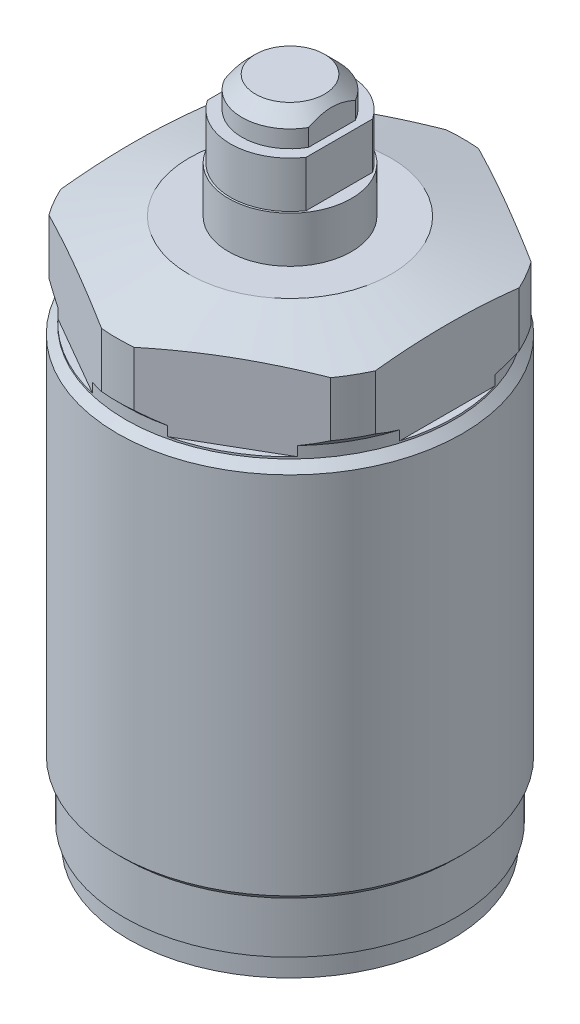
from build123d import *

# Parameters (mm, degrees)
SKETCH2_OUTSIDE_W       = 66.07
SKETCH2_OUTSIDE_H       = 66.07
CUT_EXTRUDE1_DEPTH      = 12
CHAMFER1_SIZE           = 1.754
SKETCH5_W               = 2.285
SKETCH5_H               = 3.988
CUT_EXTRUDE2_DEPTH      = 23.5
CUT_EXTRUDE2_DEPTH_BACK = 23.5
SKETCH6_W               = 1.575
SKETCH6_H               = 6.02
CUT_EXTRUDE3_DEPTH      = 23.5
CUT_EXTRUDE3_DEPTH_BACK = 23.5


with BuildPart() as part:
    # Sketch1 → Revolve1 (revolve)
    with BuildSketch(Plane.XY, mode=Mode.PRIVATE) as revolve1_sk:
        Polygon((-21.575, 0), (-21, 0), (-21, -2.75), (0, -2.75), (0, 68.25), (-13.125, 68.25), (-22.5, 65.737976321), (-22.5, 58.625), (-21.375, 57.5), (-21.375, 56), (-22.425, 54.95), (-22.425, 7.5), (-21.575, 6.65), align=None)
    revolve(revolve1_sk.sketch.rotate(Axis((0, 0, 0), (0, -1, 0)), 270), axis=Axis((0, 0, 0), (0, -1, 0)))  # turned: the seam where the file's is

    # Sketch2 outside → Cut-Extrude1 (cut)
    with BuildSketch(Plane(origin=(0, 68.25, 0), x_dir=(1, 0, 0), z_dir=(0, 1, 0))):
        Rectangle(SKETCH2_OUTSIDE_W, SKETCH2_OUTSIDE_H)
        Polygon((0, 23.625173015), (-20.46, 11.812586508), (-20.46, -11.812586508), (0, -23.625173015), (20.46, -11.812586508), (20.46, 11.812586508), align=None, mode=Mode.SUBTRACT)
    extrude(amount=-CUT_EXTRUDE1_DEPTH, mode=Mode.SUBTRACT)

    # Sketch4 → Revolve2 (revolve)
    with BuildSketch(Plane.XY, mode=Mode.PRIVATE) as revolve2_sk:
        Polygon((0, 84.25), (-6.25, 84.25), (-6.25, 80.262), (-7.745, 80.262), (-7.745, 74.242), (-8, 74.242), (-8, 68.25), (0, 68.25), align=None)
    revolve(revolve2_sk.sketch.rotate(Axis((0, 0, 0), (0, 1, 0)), 90), axis=Axis((0, 0, 0), (0, 1, 0)))  # turned: the seam where the file's is

    # Chamfer1
    chamfer1_edges = [part.edges().sort_by_distance(p)[0] for p in [
        (0, 84.25, -6.25),
    ]]
    chamfer(chamfer1_edges, length=CHAMFER1_SIZE)

    # Sketch5 → Cut-Extrude2 (cut, two sides)
    with BuildSketch(Plane.XY) as cut_extrude2_sk:
        with Locations((-6.6025, 82.256)):
            Rectangle(SKETCH5_W, SKETCH5_H)
        with Locations((6.6025, 82.256)):
            Rectangle(SKETCH5_W, SKETCH5_H)
    extrude(amount=CUT_EXTRUDE2_DEPTH, mode=Mode.SUBTRACT)
    extrude(cut_extrude2_sk.sketch, amount=-CUT_EXTRUDE2_DEPTH_BACK, mode=Mode.SUBTRACT)

    # Sketch6 → Cut-Extrude3 (cut, two sides)
    with BuildSketch(Plane.XY) as cut_extrude3_sk:
        with Locations((-7.2125, 77.252)):
            Rectangle(SKETCH6_W, SKETCH6_H)
        with Locations((7.2125, 77.252)):
            Rectangle(SKETCH6_W, SKETCH6_H)
    extrude(amount=CUT_EXTRUDE3_DEPTH, mode=Mode.SUBTRACT)
    extrude(cut_extrude3_sk.sketch, amount=-CUT_EXTRUDE3_DEPTH_BACK, mode=Mode.SUBTRACT)


solid = part.part
